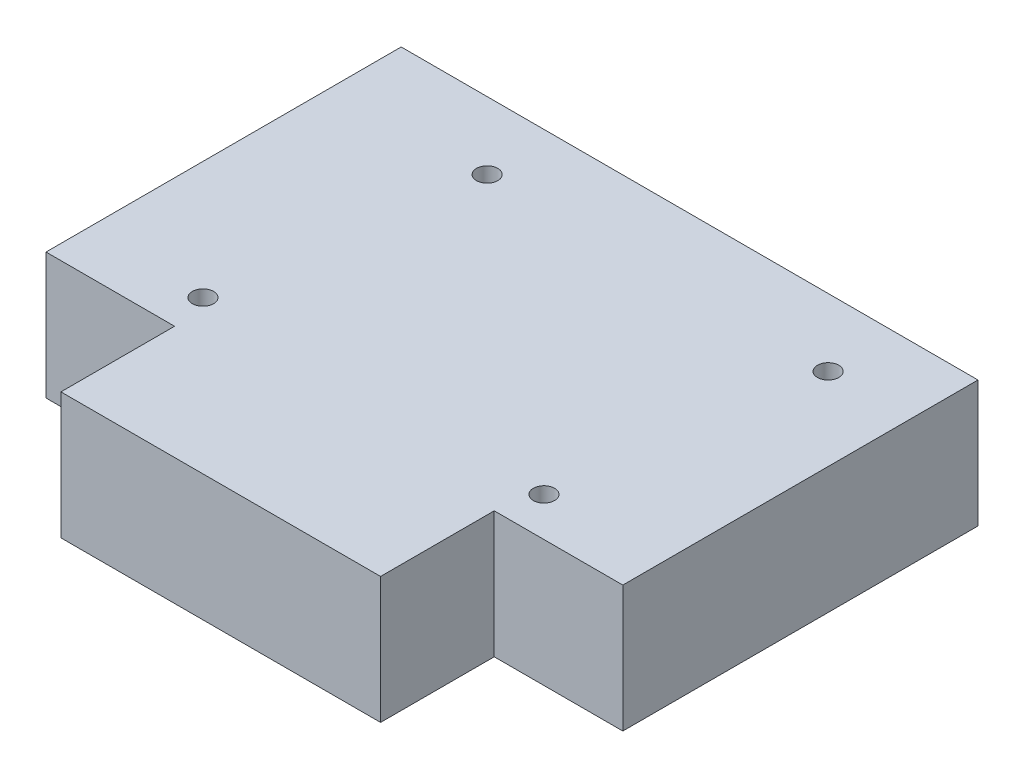
from build123d import *

# Parameters (mm, degrees)
SKETCH1_R           = 1.5
BOSS_EXTRUDE1_DEPTH = 17.8


with BuildPart() as part:
    # Sketch1 → Boss-Extrude1 (new body)
    with BuildSketch(Plane(origin=(0, 0, 0), x_dir=(1, 0, 0), z_dir=(0, 1, 0))):
        Polygon((-40.6, -25), (-22.5, -25), (-22.5, -41), (22.5, -41), (22.5, -25), (40.6, -25), (40.6, 25), (-40.6, 25), align=None)
        with Locations((-19, 15.5)):
            Circle(SKETCH1_R, mode=Mode.SUBTRACT)
        with Locations((29, 15.5)):
            Circle(SKETCH1_R, mode=Mode.SUBTRACT)
        with Locations((-24, -19.5)):
            Circle(SKETCH1_R, mode=Mode.SUBTRACT)
        with Locations((24, -19.5)):
            Circle(SKETCH1_R, mode=Mode.SUBTRACT)
    extrude(amount=BOSS_EXTRUDE1_DEPTH)


solid = part.part
